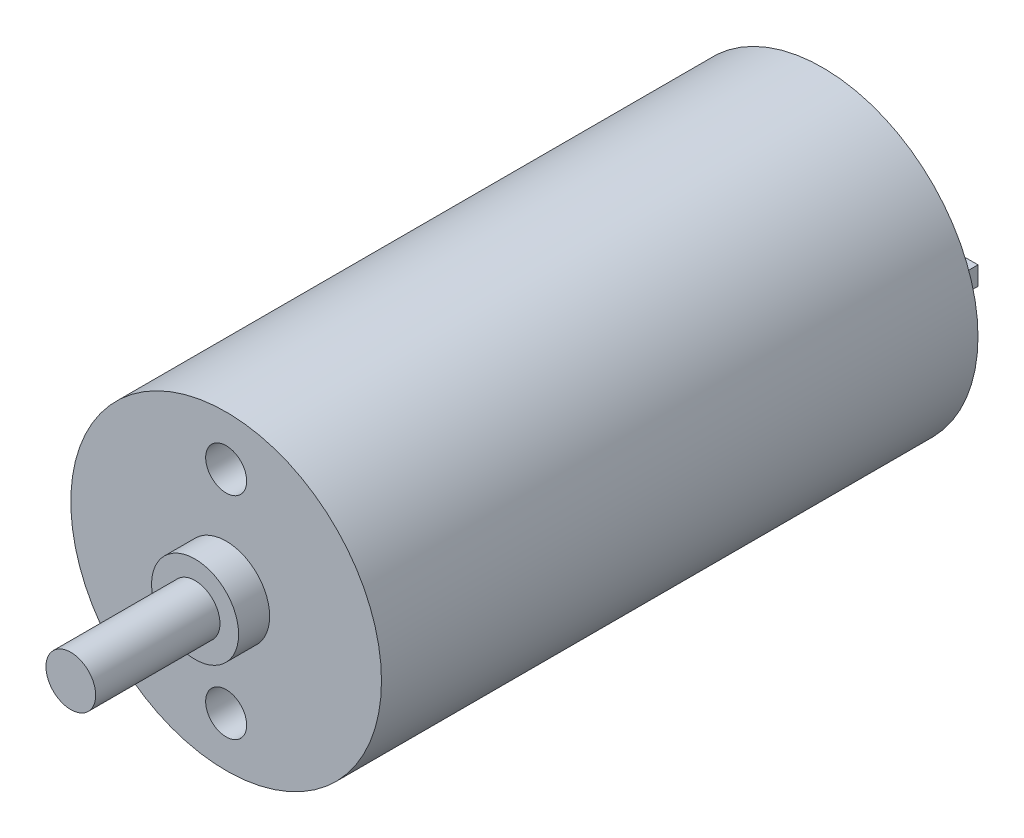
from build123d import *

# Parameters (mm, degrees)
SKICA1_R                 = 12.5
P_IDAT_VYSUNUT_M1_DEPTH  = 48
SKICA2_R                 = 3.5
P_IDAT_VYSUNUT_M2_DEPTH  = 2.5
SKICA3_R                 = 2
P_IDAT_VYSUNUT_M3_DEPTH  = 10
SKICA4_W                 = 4
SKICA4_H                 = 1.5
P_IDAT_VYSUNUT_M4_DEPTH  = 4
SKICA5_R                 = 1.65
ODEBRAT_VYSUNUT_M1_DEPTH = 4


with BuildPart() as part:
    # Skica1 → Přidat vysunutím1 (new body)
    with BuildSketch(Plane.XY):
        Circle(SKICA1_R)
    extrude(amount=P_IDAT_VYSUNUT_M1_DEPTH)

    # Skica2 → Přidat vysunutím2 (add)
    with BuildSketch(Plane.XY.offset(48)):
        Circle(SKICA2_R)
    extrude(amount=P_IDAT_VYSUNUT_M2_DEPTH)

    # Skica3 → Přidat vysunutím3 (add)
    with BuildSketch(Plane.XY.offset(50.5)):
        Circle(SKICA3_R)
    extrude(amount=P_IDAT_VYSUNUT_M3_DEPTH)

    # Skica4 → Přidat vysunutím4 (add)
    with BuildSketch(Plane(origin=(0, 0, 0), x_dir=(-1, 0, 0), z_dir=(0, 0, -1))):
        with Locations((-6.5, 0.25)):
            Rectangle(SKICA4_W, SKICA4_H)
        with Locations((6.5, 0.25)):
            Rectangle(SKICA4_W, SKICA4_H)
    extrude(amount=P_IDAT_VYSUNUT_M4_DEPTH)

    # Skica5 → Odebrat vysunutím1 (cut)
    with BuildSketch(Plane.XY.offset(48)):
        with Locations((0, 8.5)):
            Circle(SKICA5_R)
        with Locations((0, -8.5)):
            Circle(SKICA5_R)
    extrude(amount=-ODEBRAT_VYSUNUT_M1_DEPTH, mode=Mode.SUBTRACT)


solid = part.part
